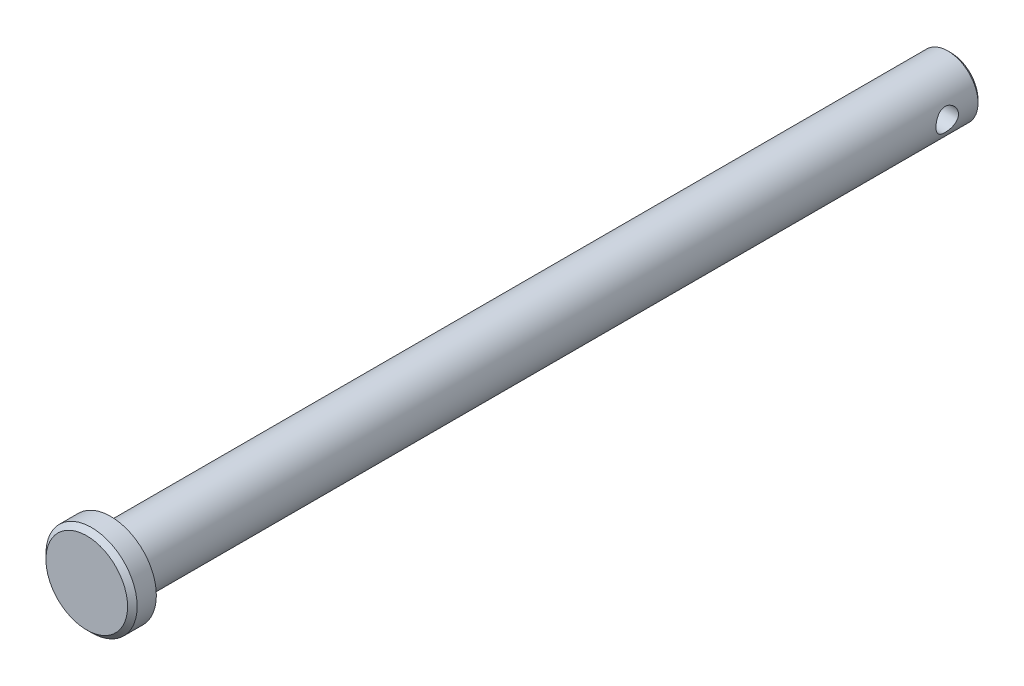
from build123d import *

# Parameters (mm, degrees)
SKETCH1_R           = 3.175
EXTRUDE1_DEPTH      = 44.45
SKETCH2_R           = 4.826
EXTRUDE2_DEPTH      = 2.54
CHAMFER1_SIZE       = 0.508
SKETCH3_R           = 1.190625
EXTRUDE3_DEPTH      = 5.826
EXTRUDE3_DEPTH_BACK = 5.826
CHAMFER2_SIZE       = 0.3175


with BuildPart() as part:
    # Sketch1 → Extrude1 (new body, symmetric)
    with BuildSketch(Plane.XY):
        Circle(SKETCH1_R)
    extrude(amount=EXTRUDE1_DEPTH, both=True)

    # Sketch2 → Extrude2 (add)
    with BuildSketch(Plane.XY.offset(44.45)):
        Circle(SKETCH2_R)
    extrude(amount=EXTRUDE2_DEPTH)

    # Chamfer1
    chamfer1_edges = [part.edges().sort_by_distance(p)[0] for p in [
        (-4.826, 0, 46.99),
    ]]
    chamfer(chamfer1_edges, length=CHAMFER1_SIZE)

    # Sketch3 → Extrude3 (cut, two sides)
    with BuildSketch(Plane(origin=(0, 0, 0), x_dir=(0, 0, -1), z_dir=(1, 0, 0))) as extrude3_sk:
        with Locations((40.878125, 0)):
            Circle(SKETCH3_R)
    extrude(amount=EXTRUDE3_DEPTH, mode=Mode.SUBTRACT)
    extrude(extrude3_sk.sketch, amount=-EXTRUDE3_DEPTH_BACK, mode=Mode.SUBTRACT)

    # Chamfer2
    chamfer2_edges = [part.edges().sort_by_distance(p)[0] for p in [
        (-3.175, 0, -44.45),
    ]]
    chamfer(chamfer2_edges, length=CHAMFER2_SIZE)


solid = part.part
